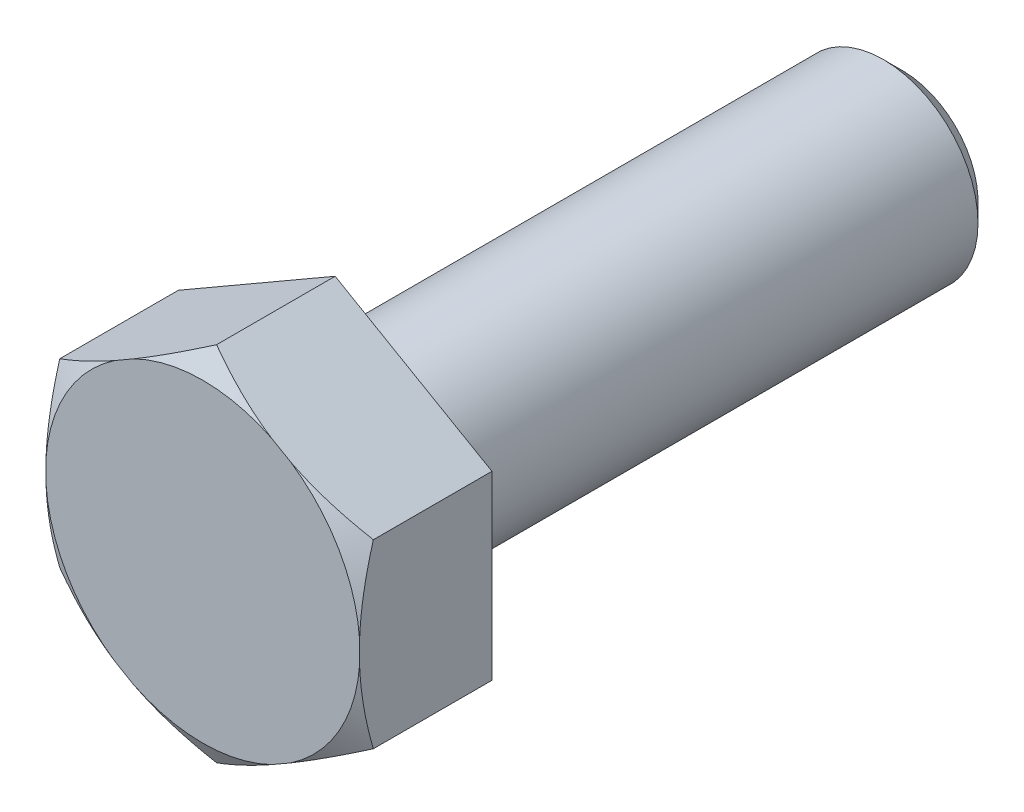
from build123d import *

# Parameters (mm, degrees)
SKETCH_2_OUTSIDE_W  = 13.726
SKETCH_2_OUTSIDE_H  = 13.726
CUT_EXTRUDE_1_DEPTH = 2.8
CHAMFER_1_SIZE      = 0.4
FILLET_1_R          = 0.4


with BuildPart() as part:
    # Эскиз1 → Повернуть1 (revolve)
    with BuildSketch(Plane(origin=(0, 0, 0), x_dir=(1, 0, 0), z_dir=(0, 1, 0))):
        Polygon((0, 0), (-4, 0), (-4, 2.8), (-2, 2.8), (-2, 14.8), (0, 14.8), align=None)
    revolve(axis=Axis((0, 0, -14.8), (0, 0, 1)))

    # Эскиз2 outside → Вырез-Вытянуть1 (cut)
    with BuildSketch(Plane.XY):
        Rectangle(SKETCH_2_OUTSIDE_W, SKETCH_2_OUTSIDE_H)
        Polygon((0, 3.83), (-3.316877296, 1.915), (-3.316877296, -1.915), (0, -3.83), (3.316877296, -1.915), (3.316877296, 1.915), align=None, mode=Mode.SUBTRACT)
    extrude(amount=-CUT_EXTRUDE_1_DEPTH, mode=Mode.SUBTRACT)

    # Эскиз3 → Вырез-Повернуть1 (revolve, cut)
    with BuildSketch(Plane(origin=(0, 0, 0), x_dir=(0, 0, -1), z_dir=(1, 0, 0))):
        Polygon((0, 3.83), (0.291561886, 3.83), (0, 3.325), align=None)
    revolve(axis=Axis((0, 0, 0), (0, 0, 1)), mode=Mode.SUBTRACT)

    # Фаска1
    chamfer_1_edges = [part.edges().sort_by_distance(p)[0] for p in [
        (2, 0, -14.8),
    ]]
    chamfer(chamfer_1_edges, length=CHAMFER_1_SIZE)

    # Скругление1
    fillet_1_edges = [part.edges().sort_by_distance(p)[0] for p in [
        (2, 0, -2.8),
    ]]
    fillet(fillet_1_edges, radius=FILLET_1_R)


solid = part.part
